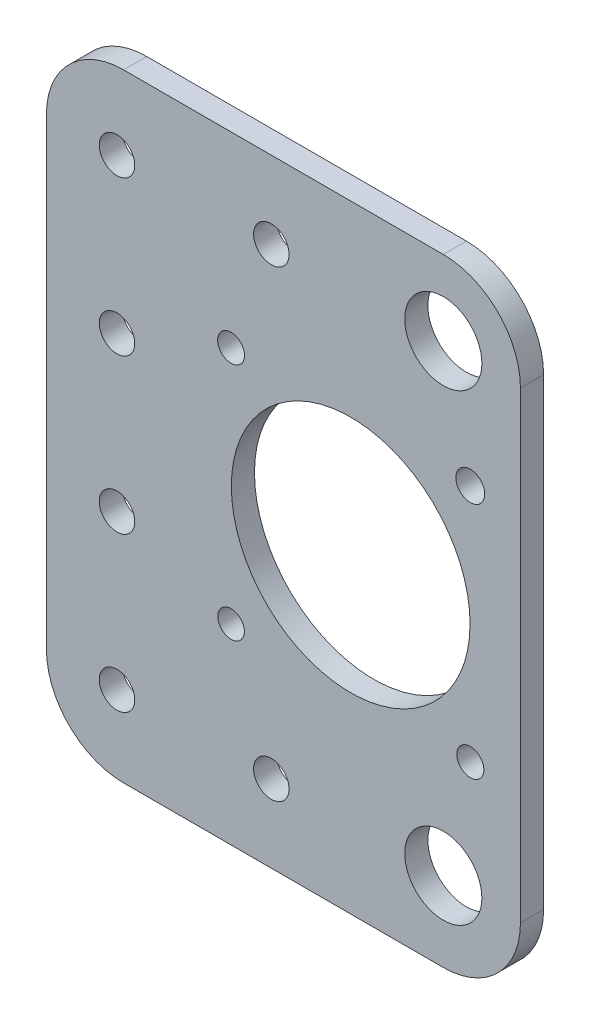
from build123d import *

# Parameters (mm, degrees)
SKETCH1_R           = 2.3
SKETCH1_R_2         = 1.737885662
SKETCH1_R_3         = 1.873200063
SKETCH1_R_4         = 1.722278718
SKETCH1_R_5         = 1.754205974
SKETCH1_R_6         = 15.469551166
SKETCH1_R_7         = 5
BOSS_EXTRUDE1_DEPTH = 3


with BuildPart() as part:
    # Sketch1 → Boss-Extrude1 (new body)
    with BuildSketch(Plane.XY):
        with BuildLine():
            Line((116.525823666, -71.866196008), (157.960700719, -71.866196008))
            ThreePointArc((157.960700719, -71.866196008), (165.031768531, -74.795128196), (167.960700719, -81.866196008))
            Line((167.960700719, -81.866196008), (167.960700719, -141.896756479))
            ThreePointArc((167.960700719, -141.896756479), (165.031768531, -148.967824291), (157.960700719, -151.896756479))
            Line((157.960700719, -151.896756479), (116.525823666, -151.896756479))
            ThreePointArc((116.525823666, -151.896756479), (109.454755854, -148.967824291), (106.525823666, -141.896756479))
            Line((106.525823666, -141.896756479), (106.525823666, -81.866196008))
            ThreePointArc((106.525823666, -81.866196008), (109.454755854, -74.795128196), (116.525823666, -71.866196008))
        make_face()
        with Locations((115.674612816, -101.866196008)):
            Circle(SKETCH1_R, mode=Mode.SUBTRACT)
        with Locations((115.674612816, -121.866196008)):
            Circle(SKETCH1_R, mode=Mode.SUBTRACT)
        with Locations((135.674612816, -141.866196008)):
            Circle(SKETCH1_R, mode=Mode.SUBTRACT)
        with Locations((135.674612816, -81.866196008)):
            Circle(SKETCH1_R, mode=Mode.SUBTRACT)
        with Locations((115.674612816, -81.866196008)):
            Circle(SKETCH1_R, mode=Mode.SUBTRACT)
        with Locations((115.674612816, -141.866196008)):
            Circle(SKETCH1_R, mode=Mode.SUBTRACT)
        with Locations((130.460700719, -96.091712302)):
            Circle(SKETCH1_R_2, mode=Mode.SUBTRACT)
        with Locations((161.460700719, -96.091712302)):
            Circle(SKETCH1_R_3, mode=Mode.SUBTRACT)
        with Locations((130.460700719, -127.091712302)):
            Circle(SKETCH1_R_4, mode=Mode.SUBTRACT)
        with Locations((161.460700719, -127.091712302)):
            Circle(SKETCH1_R_5, mode=Mode.SUBTRACT)
        with Locations((145.960700719, -111.591712302)):
            Circle(SKETCH1_R_6, mode=Mode.SUBTRACT)
        with Locations((157.960700719, -81.591712302)):
            Circle(SKETCH1_R_7, mode=Mode.SUBTRACT)
        with Locations((157.960700719, -141.591712302)):
            Circle(SKETCH1_R_7, mode=Mode.SUBTRACT)
    extrude(amount=BOSS_EXTRUDE1_DEPTH)


solid = part.part
